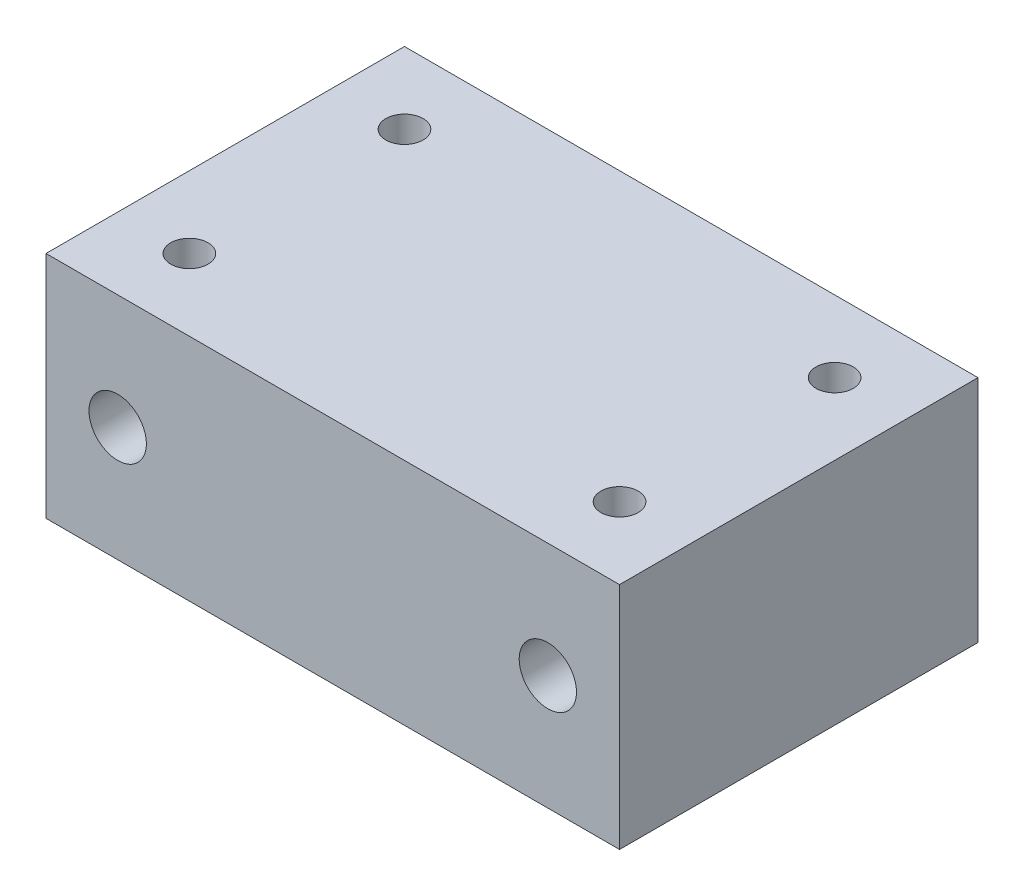
from build123d import *

# Parameters (mm, degrees)
SKETCH3_W           = 80
SKETCH3_H           = 50
BOSS_EXTRUDE1_DEPTH = 32
SKETCH4_R           = 2.6
CUT_EXTRUDE1_DEPTH  = 5
SKETCH5_R           = 4
CUT_EXTRUDE2_DEPTH  = 65


with BuildPart() as part:
    # Sketch3 → Boss-Extrude1 (new body)
    with BuildSketch(Plane(origin=(0, 0, 0), x_dir=(1, 0, 0), z_dir=(0, 1, 0))):
        Rectangle(SKETCH3_W, SKETCH3_H)
    extrude(amount=BOSS_EXTRUDE1_DEPTH)

    # Sketch4 → Cut-Extrude1 (cut)
    with BuildSketch(Plane(origin=(0, 32, 0), x_dir=(1, 0, 0), z_dir=(0, 1, 0))):
        with Locations((-30, 15)):
            Circle(SKETCH4_R)
        with Locations((30, 15)):
            Circle(SKETCH4_R)
        with Locations((30, -15)):
            Circle(SKETCH4_R)
        with Locations((-30, -15)):
            Circle(SKETCH4_R)
    extrude(amount=-CUT_EXTRUDE1_DEPTH, mode=Mode.SUBTRACT)

    # Sketch5 → Cut-Extrude2 (cut)
    with BuildSketch(Plane(origin=(0, 0, -25), x_dir=(-1, 0, 0), z_dir=(0, 0, -1))):
        with Locations((-30, 16)):
            Circle(SKETCH5_R)
        with Locations((30, 16)):
            Circle(SKETCH5_R)
    extrude(amount=-CUT_EXTRUDE2_DEPTH, mode=Mode.SUBTRACT)


solid = part.part
